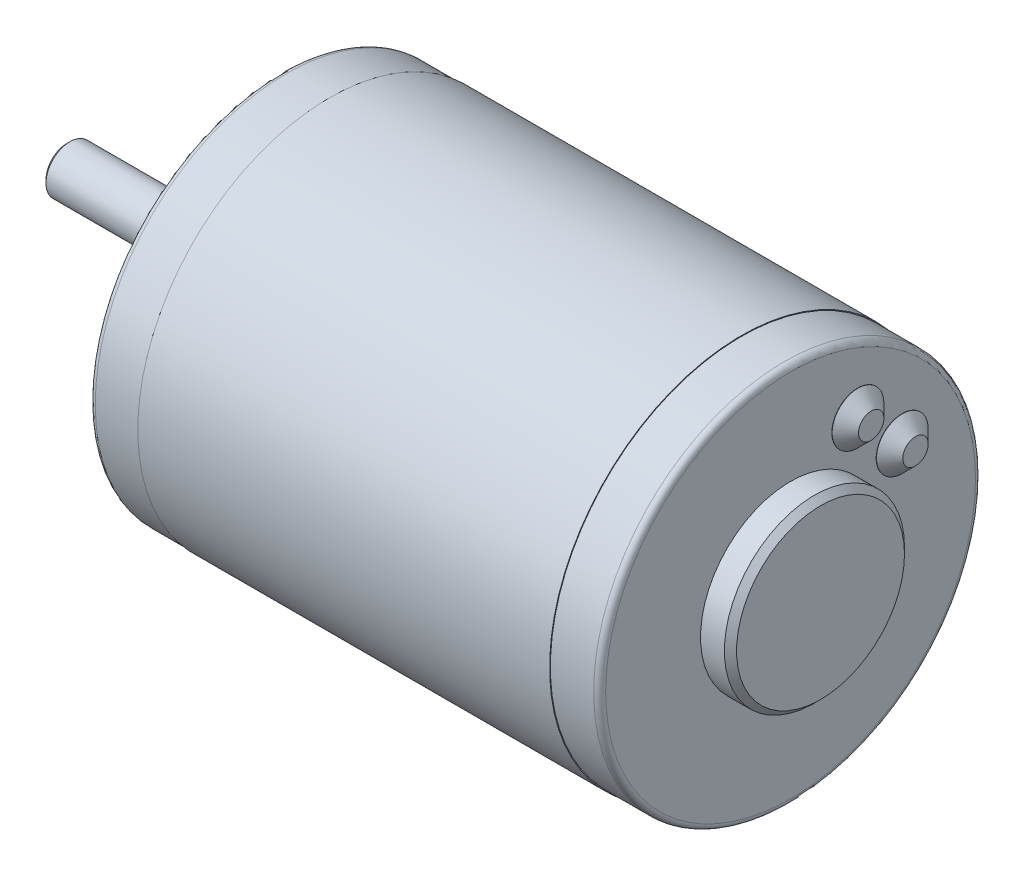
from build123d import *

# Parameters (mm, degrees)
SKETCH1_W                       = 68.7568
SKETCH1_H                       = 32.004
SKETCH2_R                       = 31.877
BOSS_EXTRUDE1_DEPTH             = 8.2296
SKETCH3_R                       = 15.0368
BOSS_EXTRUDE2_DEPTH             = 5
SKETCH4_R                       = 31.877
BOSS_EXTRUDE3_DEPTH             = 8.2296
SKETCH5_R                       = 9.525
BOSS_EXTRUDE4_DEPTH             = 4
SKETCH6_R                       = 4
BOSS_EXTRUDE5_DEPTH             = 31.6
F_21_0_159_DIAMETER_HOLE1_D     = 4.0386
F_21_0_159_DIAMETER_HOLE1_DEPTH = 13.6144
F_21_0_159_DIAMETER_HOLE1_TIP   = 1.213317848
CHAMFER1_SIZE                   = 1.016
CHAMFER2_SIZE                   = 0.5
FILLET1_R                       = 1


with BuildPart() as part:
    # Sketch1 → Revolve1 (revolve)
    with BuildSketch(Plane.XY):
        with Locations((42.608, 16.002)):
            Rectangle(SKETCH1_W, SKETCH1_H)
    revolve(axis=Axis((8.2296, 0, 0), (1, 0, 0)))

    # Sketch2 → Boss-Extrude1 (add)
    with BuildSketch(Plane(origin=(76.9864, 0, 0), x_dir=(0, 0, -1), z_dir=(1, 0, 0))):
        Circle(SKETCH2_R)
    extrude(amount=BOSS_EXTRUDE1_DEPTH)

    # Sketch3 → Boss-Extrude2 (add)
    with BuildSketch(Plane(origin=(85.216, 0, 0), x_dir=(0, 0, -1), z_dir=(1, 0, 0))):
        Circle(SKETCH3_R)
    extrude(amount=BOSS_EXTRUDE2_DEPTH)

    # Sketch4 → Boss-Extrude3 (add)
    with BuildSketch(Plane.ZY.offset(-8.2296)):
        Circle(SKETCH4_R)
    extrude(amount=BOSS_EXTRUDE3_DEPTH)

    # Sketch5 → Boss-Extrude4 (add)
    with BuildSketch(Plane.ZY):
        Circle(SKETCH5_R)
    extrude(amount=BOSS_EXTRUDE4_DEPTH)

    # Sketch6 → Boss-Extrude5 (add)
    with BuildSketch(Plane.ZY.offset(4)):
        Circle(SKETCH6_R)
    extrude(amount=BOSS_EXTRUDE5_DEPTH)

    # Sketch8 → Revolve2 (revolve)
    with BuildSketch(Plane.XY.offset(-18.607090683)):
        Polygon((85.216, 15.525359639), (85.216, 11.207359639), (87.4639, 11.207359639), (87.4639, 13.325359639), (85.2639, 15.525359639), align=None)
    revolve(axis=Axis((85.216, 11.207359639, -18.607090683), (1, 0, 0)))

    # Sketch9 → Revolve3 (revolve)
    with BuildSketch(Plane.XY.offset(-11.207359639)):
        Polygon((85.216, 22.925090683), (85.216, 18.607090683), (87.4639, 18.607090683), (87.4639, 20.725090683), (85.2639, 22.925090683), align=None)
    revolve(axis=Axis((85.216, 18.607090683, -11.207359639), (1, 0, 0)))

    # #21 (0.159) Diameter Hole1
    with Locations(Plane.ZY):
        with Locations((0, 25.4), (0, -25.4)):
            Hole(F_21_0_159_DIAMETER_HOLE1_D / 2, depth=F_21_0_159_DIAMETER_HOLE1_DEPTH)
            with Locations((0, 0, -(F_21_0_159_DIAMETER_HOLE1_DEPTH + F_21_0_159_DIAMETER_HOLE1_TIP / 2))):  # 118° drill point
                Cone(0, F_21_0_159_DIAMETER_HOLE1_D / 2, F_21_0_159_DIAMETER_HOLE1_TIP, mode=Mode.SUBTRACT)

    # Chamfer1
    chamfer1_edges = [part.edges().sort_by_distance(p)[0] for p in [
        (90.216, 0, 15.0368),
        (-4, 0, -9.525),
    ]]
    chamfer(chamfer1_edges, length=CHAMFER1_SIZE)

    # Chamfer2
    chamfer2_edges = [part.edges().sort_by_distance(p)[0] for p in [
        (-35.6, 0, -4),
    ]]
    chamfer(chamfer2_edges, length=CHAMFER2_SIZE)

    # Fillet1
    fillet1_edges = [part.edges().sort_by_distance(p)[0] for p in [
        (0, 0, -31.877),
        (85.216, 0, 31.877),
    ]]
    fillet(fillet1_edges, radius=FILLET1_R)


solid = part.part
